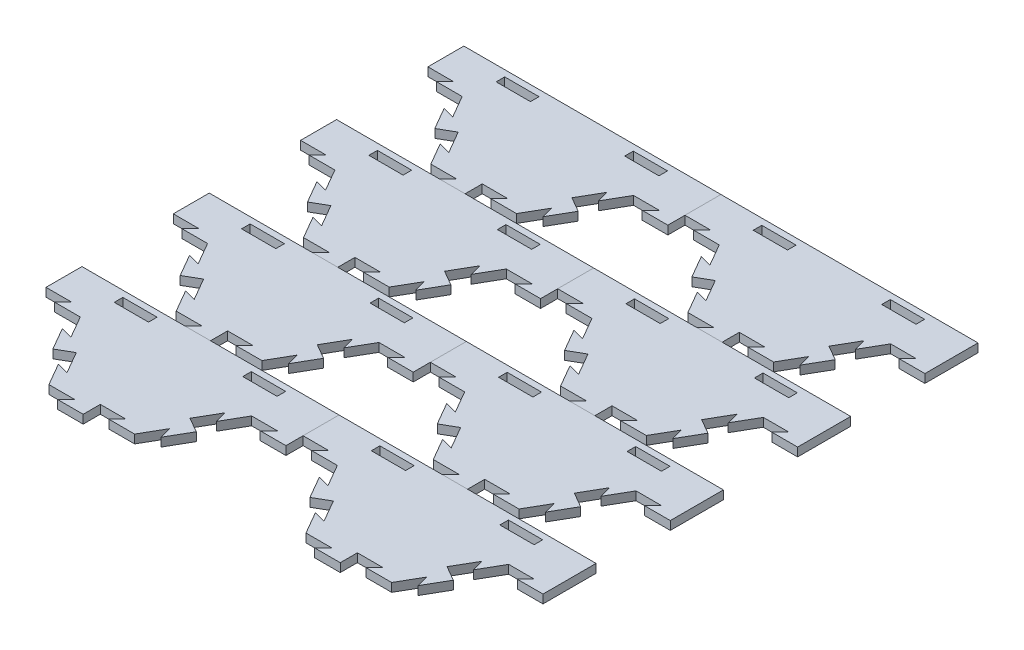
from build123d import *

# Parameters (mm, degrees)
BOSS_EXTRUDE1_DEPTH = 6.35
CUT_EXTRUDE4_DEPTH  = 7.35
BOSS_EXTRUDE4_DEPTH = 6.35
CIRPATTERN7_COUNT   = 6
SKETCH12_W          = 127
SKETCH12_H          = 61.34261314
CUT_EXTRUDE5_DEPTH  = 7.35
SKETCH13_W          = 190.5
SKETCH13_H          = 6.35
BOSS_EXTRUDE5_DEPTH = 32.995561898
CUT_EXTRUDE6_DEPTH  = 7.35
BOSS_EXTRUDE6_DEPTH = 6.35
SKETCH17_W          = 25.4
SKETCH17_H          = 6.35
CUT_EXTRUDE8_DEPTH  = 7.35
LPATTERN1_COUNT     = 2
LPATTERN1_PITCH     = 190.5
LPATTERN2_COUNT     = 4
LPATTERN2_PITCH     = 94.338175052


with BuildPart() as part:
    # Sketch1 → Boss-Extrude1 (new body)
    with BuildSketch(Plane(origin=(0, 0, 0), x_dir=(1, 0, 0), z_dir=(0, 1, 0))):
        Polygon((63.5, 0), (31.75, 54.99261314), (-31.75, 54.99261314), (-63.5, 0), (-31.75, -54.99261314), (31.75, -54.99261314), align=None)
    extrude(amount=-BOSS_EXTRUDE1_DEPTH)

    # Sketch10 → Cut-Extrude4 (cut, through all)
    with BuildSketch(Plane(origin=(0, 0, 0), x_dir=(1, 0, 0), z_dir=(0, 1, 0))):
        Polygon((41.275, 38.494829198), (32.600738686, 40.819090512), (42.125738686, 24.32130657), (47.625, 27.49630657), align=None)
    cut_extrude4 = extrude(amount=-CUT_EXTRUDE4_DEPTH, mode=Mode.SUBTRACT)

    # Sketch11 → Boss-Extrude4 (add)
    with BuildSketch(Plane(origin=(0, 0, 0), x_dir=(1, 0, 0), z_dir=(0, 1, 0))):
        Polygon((47.625, 27.49630657), (53.124261314, 30.67130657), (62.649261314, 14.173522628), (53.975, 16.497783942), align=None)
    boss_extrude4 = extrude(amount=-BOSS_EXTRUDE4_DEPTH)

    # CirPattern7: Cut-Extrude4, Boss-Extrude4 ×6 about axis
    cirpattern7_axis = Axis((0, 0, 0), (0, 1, 0))
    for i in range(1, CIRPATTERN7_COUNT):
        add(cut_extrude4.rotate(cirpattern7_axis, i * 360 / CIRPATTERN7_COUNT), mode=Mode.SUBTRACT)
        add(boss_extrude4.rotate(cirpattern7_axis, i * 360 / CIRPATTERN7_COUNT))

    # Sketch12 → Cut-Extrude5 (cut, through all)
    with BuildSketch(Plane(origin=(0, 0, 0), x_dir=(1, 0, 0), z_dir=(0, 1, 0))):
        with Locations((0, 30.67130657)):
            Rectangle(SKETCH12_W, SKETCH12_H)
    extrude(amount=-CUT_EXTRUDE5_DEPTH, mode=Mode.SUBTRACT)

    # Sketch13 → Boss-Extrude5 (add)
    with BuildSketch(Plane(origin=(0, 0, 0), x_dir=(-1, 0, 0), z_dir=(0, 0, -1))):
        with Locations((0, -3.175)):
            Rectangle(SKETCH13_W, SKETCH13_H)
    extrude(amount=BOSS_EXTRUDE5_DEPTH)

    # Sketch15 → Cut-Extrude6 (cut, through all)
    with BuildSketch(Plane(origin=(0, 0, 0), x_dir=(1, 0, 0), z_dir=(0, 1, 0))):
        Polygon((-82.55, 0), (-76.2, 6.35), (-95.25, 6.35), (-95.25, 0), align=None)
    extrude(amount=-CUT_EXTRUDE6_DEPTH, mode=Mode.SUBTRACT)

    # Sketch16 → Boss-Extrude6 (add)
    with BuildSketch(Plane(origin=(0, 0, 0), x_dir=(1, 0, 0), z_dir=(0, 1, 0))):
        Polygon((82.55, 0), (76.2, -6.35), (95.25, -6.35), (95.25, 0), align=None)
    extrude(amount=-BOSS_EXTRUDE6_DEPTH)

    # Sketch17 → Cut-Extrude8 (cut, through all)
    with BuildSketch(Plane(origin=(0, 0, 0), x_dir=(1, 0, 0), z_dir=(0, 1, 0))):
        with Locations((-47.625, 25.172035635)):
            Rectangle(SKETCH17_W, SKETCH17_H)
        with Locations((47.625, 25.172035635)):
            Rectangle(SKETCH17_W, SKETCH17_H)
    extrude(amount=-CUT_EXTRUDE8_DEPTH, mode=Mode.SUBTRACT)


with BuildPart() as lpattern1_1:
    # LPattern1: pattern copy
    add(part.part.moved(Location(Vector(1, 0, 0) * (1 * LPATTERN1_PITCH))))


with BuildPart() as lpattern2_1:
    # LPattern2: pattern copy
    add(lpattern1_1.part.moved(Location(Vector(0, 0, 1) * (1 * LPATTERN2_PITCH))))


with BuildPart() as lpattern2_2:
    # LPattern2: pattern copy
    add(lpattern1_1.part.moved(Location(Vector(0, 0, 1) * (2 * LPATTERN2_PITCH))))


with BuildPart() as lpattern2_3:
    # LPattern2: pattern copy
    add(lpattern1_1.part.moved(Location(Vector(0, 0, 1) * (3 * LPATTERN2_PITCH))))


with BuildPart() as lpattern2_4:
    # LPattern2: pattern copy
    add(part.part.moved(Location(Vector(0, 0, 1) * (1 * LPATTERN2_PITCH))))


with BuildPart() as lpattern2_5:
    # LPattern2: pattern copy
    add(part.part.moved(Location(Vector(0, 0, 1) * (2 * LPATTERN2_PITCH))))


with BuildPart() as lpattern2_6:
    # LPattern2: pattern copy
    add(part.part.moved(Location(Vector(0, 0, 1) * (3 * LPATTERN2_PITCH))))


solid = Compound([part.part, lpattern1_1.part, lpattern2_1.part, lpattern2_2.part, lpattern2_3.part, lpattern2_4.part, lpattern2_5.part, lpattern2_6.part])
